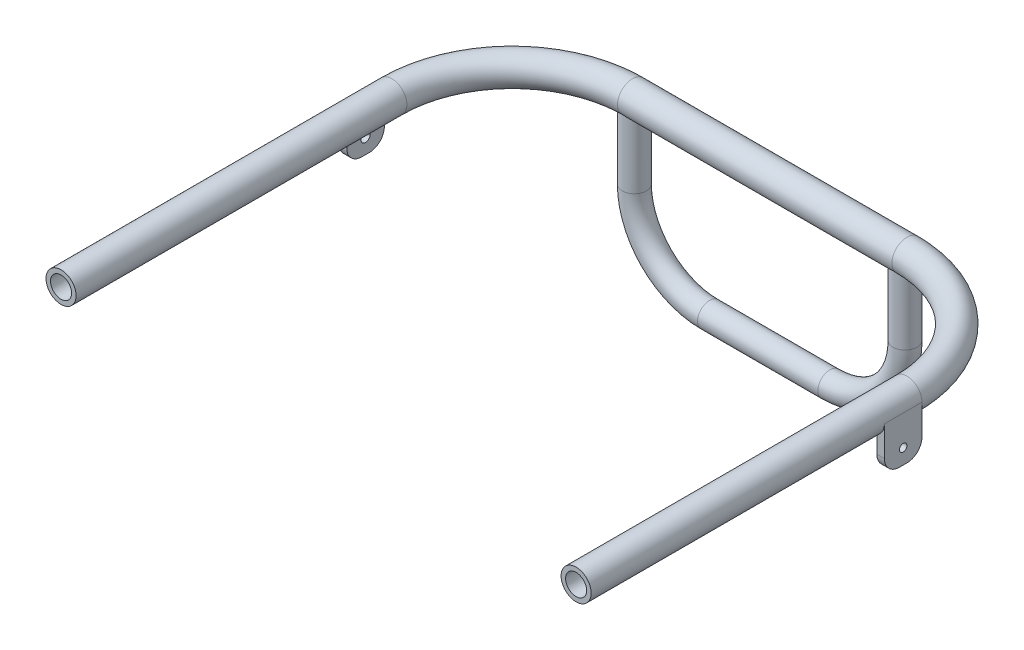
from build123d import *

# Parameters (mm, degrees)
SWEEP_THIN1_PROFILE_R   = 10
SWEEP_THIN1_PROFILE_R_2 = 7
SWEEP_THIN2_PROFILE_R   = 8
SWEEP_THIN2_PROFILE_R_2 = 5
SKETCH17_R              = 3
BOSS_EXTRUDE1_DEPTH     = 5
SKETCH21_R              = 2.5
BOSS_EXTRUDE2_DEPTH     = 5


with BuildPart() as part:
    # Sweep-Thin1: sweep along a path in Sketch1
    with BuildLine(Plane(origin=(0, 0, 0), x_dir=(1, 0, 0), z_dir=(0, 1, 0))) as sweep_thin1_path:
        Line((342.5, -300), (342.5, -80))
        ThreePointArc((342.5, -80), (319.068542495, -23.431457505), (262.5, 0))
        Line((262.5, 0), (80, 0))
        ThreePointArc((80, 0), (23.431457505, -23.431457505), (0, -80))
        Line((0, -80), (0, -300))
    # Sweep-Thin1 profile (on start of the path) → Sweep-Thin1 (sweep)
    with BuildSketch(Plane(origin=(342.5, 0, 300), x_dir=(-1, 0, 0), z_dir=(0, 0, -1))):
        Circle(SWEEP_THIN1_PROFILE_R)
        Circle(SWEEP_THIN1_PROFILE_R_2, mode=Mode.SUBTRACT)
    sweep(path=sweep_thin1_path.line)

    # Sweep-Thin2: sweep along a path in Sketch10
    with BuildLine(Plane.XY) as sweep_thin2_path:
        Line((261.25, 0), (261.25, -50))
        ThreePointArc((261.25, -50), (246.605339059, -85.355339059), (211.25, -100))
        Line((211.25, -100), (131.25, -100))
        ThreePointArc((131.25, -100), (95.894660941, -85.355339059), (81.25, -50))
        Line((81.25, -50), (81.25, 0))
    # Sweep-Thin2 profile (on start of the path) → Sweep-Thin2 (sweep)
    with BuildSketch(Plane(origin=(261.25, 0, 0), x_dir=(0, 0, -1), z_dir=(0, -1, 0))):
        Circle(SWEEP_THIN2_PROFILE_R)
        Circle(SWEEP_THIN2_PROFILE_R_2, mode=Mode.SUBTRACT)
    sweep(path=sweep_thin2_path.line)

    # Sketch17 → Boss-Extrude1 (add)
    with BuildSketch(Plane.ZY.offset(10)):
        with BuildLine():
            Line((80, 0), (80, -20))
            ThreePointArc((80, -20), (82.928932188, -27.071067812), (90, -30))
            Line((90, -30), (95, -30))
            ThreePointArc((95, -30), (102.071067812, -27.071067812), (105, -20))
            Line((105, -20), (105, 0))
            Line((105, 0), (80, 0))
        make_face()
        with Locations((92.5, -20)):
            Circle(SKETCH17_R, mode=Mode.SUBTRACT)
    extrude(amount=-BOSS_EXTRUDE1_DEPTH)

    # Sketch21 → Boss-Extrude2 (add)
    with BuildSketch(Plane(origin=(352.5, 0, 0), x_dir=(0, 0, -1), z_dir=(1, 0, 0))):
        with BuildLine():
            Line((-105, 0), (-105, -20))
            ThreePointArc((-105, -20), (-102.071067812, -27.071067812), (-95, -30))
            Line((-95, -30), (-90, -30))
            ThreePointArc((-90, -30), (-82.928932188, -27.071067812), (-80, -20))
            Line((-80, -20), (-80, 0))
            Line((-80, 0), (-105, 0))
        make_face()
        with Locations((-92.5, -20)):
            Circle(SKETCH21_R, mode=Mode.SUBTRACT)
    extrude(amount=-BOSS_EXTRUDE2_DEPTH)


solid = part.part
